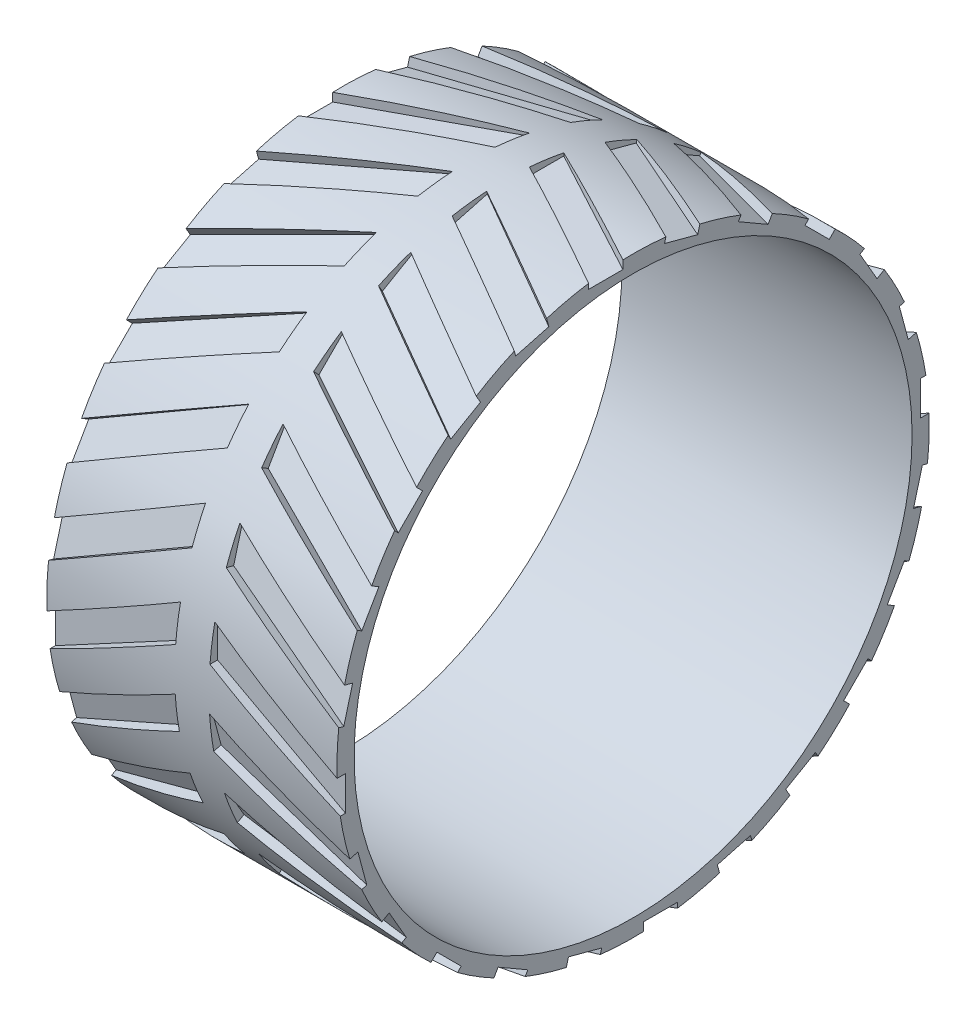
from build123d import *

# Parameters (mm, degrees)
SKETCH1_R                = 34.5
SKETCH1_R_2              = 32.5
BOSS_EXTRUDE1_DEPTH      = 33.8
CUT_EXTRUDE1_DEPTH       = 30.8
CIRPATTERN2_COUNT        = 24
BOSS_EXTRUDE2_DEPTH      = 2
BOSS_EXTRUDE2_DEPTH_BACK = 2
SKETCH4_R                = 34.5
SKETCH4_R_2              = 32.5


with BuildPart() as part:
    # Sketch1 → Boss-Extrude1 (new body)
    with BuildSketch(Plane(origin=(0, 0, 0), x_dir=(0, 0, -1), z_dir=(1, 0, 0))):
        Circle(SKETCH1_R)
        Circle(SKETCH1_R_2, mode=Mode.SUBTRACT)
    extrude(amount=BOSS_EXTRUDE1_DEPTH)

    # Sketch2 → Cut-Extrude1 (cut)
    with BuildSketch(Plane(origin=(0, 33.5, 0), x_dir=(1, 0, 0), z_dir=(0, 1, 0))):
        Polygon((16.9, 7.900383354), (16.9, 3.900383354), (0, -5.184613224), (0, -1.184613224), align=None)
        Polygon((33.8, -1.184613224), (33.8, -5.184613224), (16.9, 3.900383354), (16.9, 7.900383354), align=None)
    cut_extrude1 = extrude(amount=CUT_EXTRUDE1_DEPTH, mode=Mode.SUBTRACT)

    # CirPattern2: Cut-Extrude1 ×24 about axis
    cirpattern2_axis = Axis((0, 0, 0), (1, 0, 0))
    for i in range(1, CIRPATTERN2_COUNT):
        add(cut_extrude1.rotate(cirpattern2_axis, i * 360 / CIRPATTERN2_COUNT), mode=Mode.SUBTRACT)

    # Sketch4 → Boss-Extrude2 (add, two sides: drawn at the far end of the back side and taken through both)
    with BuildSketch(Plane.ZY.offset(-16.9).offset(-BOSS_EXTRUDE2_DEPTH_BACK)):
        with Locations(Location((0, 0, 0), (0, 0, 358.032270077))):
            Circle(SKETCH4_R)
        with Locations(Location((0, 0, 0), (0, 0, 180))):
            Circle(SKETCH4_R_2, mode=Mode.SUBTRACT)
    extrude(amount=BOSS_EXTRUDE2_DEPTH + BOSS_EXTRUDE2_DEPTH_BACK)


solid = part.part
